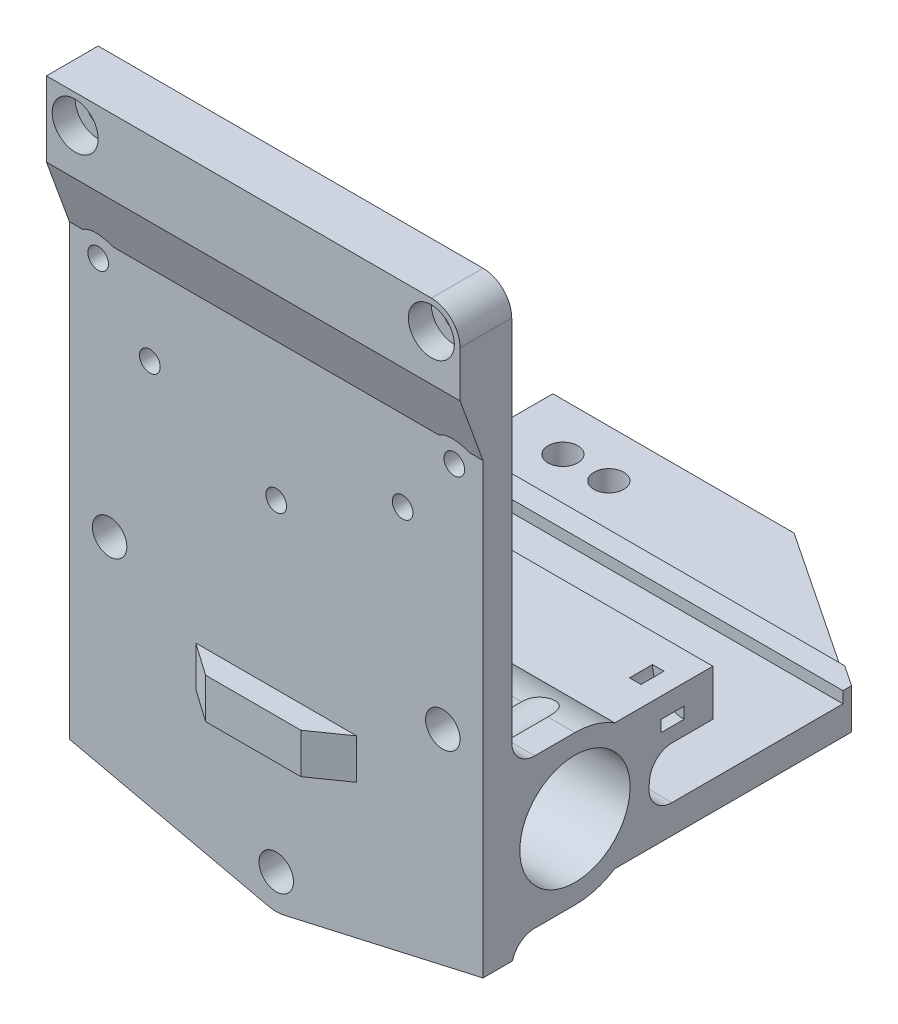
from build123d import *
from build123d.topology import SkipClean

# Parameters (mm, degrees)
SKETCH1_W               = 72
SKETCH1_H               = 102
BOSS_EXTRUDE1_DEPTH     = 5
BOSS_EXTRUDE4_DEPTH     = 72
SKETCH7_R               = 1.8
CUT_EXTRUDE4_DEPTH      = 64.071388125
SKETCH8_R               = 9.6
BOSS_EXTRUDE2_DEPTH     = 72
SKETCH9_R               = 3
CUT_EXTRUDE5_DEPTH      = 67.880490429
CUT_EXTRUDE5_DEPTH_BACK = 67.880490429
BOSS_EXTRUDE3_DEPTH     = 5
SKETCH11_R              = 5.5
CUT_EXTRUDE6_DEPTH      = 74.164198895
FILLET1_R               = 4
SKETCH13_R              = 4
CUT_EXTRUDE7_DEPTH      = 75.953318892
BOSS_EXTRUDE5_START     = -25.5
BOSS_EXTRUDE5_DEPTH     = 7
FILLET2_R               = 5
BOSS_EXTRUDE6_DEPTH     = 72
SKETCH17_W              = 72
SKETCH17_H              = 5
BOSS_EXTRUDE7_DEPTH     = 2
CHAMFER1_SIZE           = 1.1
CHAMFER1_SIZE2          = 1.905255888
SKETCH18_R              = 2.6
CUT_EXTRUDE9_DEPTH      = 2
CUT_EXTRUDE9_DEPTH_BACK = 127.588792976
BOSS_EXTRUDE8_DEPTH     = 72
FILLET3_R               = 4
SKETCH20_R              = 2.6
CUT_EXTRUDE10_DEPTH     = 8
SKETCH21_R              = 5.5
SKETCH21_R_2            = 3.5
CUT_EXTRUDE11_DEPTH     = 4
CHAMFER2_SIZE           = 1
SKETCH22_R              = 2.5
CUT_EXTRUDE12_DEPTH     = 127.588792976


with BuildPart() as part:
    # Sketch1 → Boss-Extrude1 (new body)
    with BuildSketch(Plane.XY):
        Rectangle(SKETCH1_W, SKETCH1_H)
    extrude(amount=BOSS_EXTRUDE1_DEPTH)

    # Sketch12 → Boss-Extrude4 (add)
    with BuildSketch(Plane.ZY.offset(36)):
        Polygon((5, 51), (9, 51), (9, 38), (5, 27.010090322), align=None)
    extrude(amount=-BOSS_EXTRUDE4_DEPTH)

    # Sketch7 → Cut-Extrude4 (cut, through all)
    with BuildSketch(Plane(origin=(0, 0, 0), x_dir=(-1, 0, 0), z_dir=(0, 0, -1))):
        with Locations((31, 24)):
            Circle(SKETCH7_R)
        with Locations((31, 46)):
            Circle(SKETCH7_R)
        with Locations((-31, 24)):
            Circle(SKETCH7_R)
        with Locations((-31, 46)):
            Circle(SKETCH7_R)
        with Locations((0, 3)):
            Circle(SKETCH7_R)
        with Locations((22, 13)):
            Circle(SKETCH7_R)
        with Locations((-22, 13)):
            Circle(SKETCH7_R)
    extrude(amount=-CUT_EXTRUDE4_DEPTH, mode=Mode.SUBTRACT)

    # Sketch8 → Boss-Extrude2 (add)
    with BuildSketch(Plane(origin=(36, 0, 0), x_dir=(0, 0, -1), z_dir=(1, 0, 0))):
        with BuildLine():
            Line((11, -22), (0, -22))
            Line((0, -22), (0, -48))
            Line((0, -48), (11, -48))
            ThreePointArc((11, -48), (24, -35), (11, -22))
        make_face()
        with Locations(Location((11, -35, 0), (0, 0, 90))):
            Circle(SKETCH8_R, mode=Mode.SUBTRACT)
    extrude(amount=-BOSS_EXTRUDE2_DEPTH)

    # Sketch9 → Cut-Extrude5 (cut, two sides)
    with BuildSketch(Plane(origin=(0, 0, 0), x_dir=(-1, 0, 0), z_dir=(0, 0, -1))) as cut_extrude5_sk:
        with Locations((-29, -17)):
            Circle(SKETCH9_R)
        with Locations((29, -17)):
            Circle(SKETCH9_R)
        with Locations((0, -53)):
            Circle(SKETCH9_R)
    extrude(amount=CUT_EXTRUDE5_DEPTH, mode=Mode.SUBTRACT)
    extrude(cut_extrude5_sk.sketch, amount=-CUT_EXTRUDE5_DEPTH_BACK, mode=Mode.SUBTRACT)

    # Sketch10 → Boss-Extrude3 (add)
    with BuildSketch(Plane(origin=(0, 0, 0), x_dir=(-1, 0, 0), z_dir=(0, 0, -1))):
        with BuildLine():
            Line((-36, -51), (-1.325102563, -58.851846136))
            ThreePointArc((-1.325102563, -58.851846136), (0, -59), (1.325102563, -58.851846136))
            Line((1.325102563, -58.851846136), (36, -51))
            Line((36, -51), (2.236067977, -51))
            ThreePointArc((2.236067977, -51), (0, -56), (-2.236067977, -51))
            Line((-2.236067977, -51), (-36, -51))
        make_face()
    extrude(amount=-BOSS_EXTRUDE3_DEPTH)

    # Sketch11 → Cut-Extrude6 (cut, through all)
    with BuildSketch(Plane(origin=(0, 0, 0), x_dir=(-1, 0, 0), z_dir=(0, 0, -1))):
        with Locations((-29, -17)):
            Circle(SKETCH11_R)
        with Locations((29, -17)):
            Circle(SKETCH11_R)
        with Locations((0, -53)):
            Circle(SKETCH11_R)
    extrude(amount=CUT_EXTRUDE6_DEPTH, mode=Mode.SUBTRACT)

    # Fillet1
    fillet1_edges = [part.edges().sort_by_distance(p)[0] for p in [
        (33.645643924, -22, 0),
        (0, -22, 0),
        (19.145643924, -48, 0),
        (-33.645643924, -22, 0),
        (-19.145643924, -48, 0),
    ]]
    fillet(fillet1_edges, radius=FILLET1_R)

    # Sketch13 → Cut-Extrude7 (cut, through all)
    with BuildSketch(Plane.XY.offset(5)):
        with Locations((-31, 24)):
            Circle(SKETCH13_R)
        with Locations((31, 24)):
            Circle(SKETCH13_R)
        with Locations(Location((31, 46, 0), (0, 0, 270))):
            Circle(SKETCH13_R)
        with Locations(Location((-31, 46, 0), (0, 0, 270))):
            Circle(SKETCH13_R)
    extrude(amount=CUT_EXTRUDE7_DEPTH, mode=Mode.SUBTRACT)

    # Fillet2
    fillet2_edges = [part.edges().sort_by_distance(p)[0] for p in [
        (36, 51, 4.5),
    ]]
    fillet(fillet2_edges, radius=FILLET2_R)

    # Sketch16 → Boss-Extrude6 (add)
    with SkipClean():  # the faces are left unmerged after this step: merging them gives an invalid solid
        with BuildSketch(Plane.ZY.offset(36)):
            with BuildLine():
                Line((-79.15, -41), (-18.493997598, -41))
                ThreePointArc((-18.493997598, -41), (-18.218315033, -41.328975279), (-17.92820323, -41.64529909))
                Line((-17.92820323, -41.64529909), (-17.92820323, -46))
                Line((-17.92820323, -46), (-79.15, -46))
                Line((-79.15, -46), (-79.15, -41))
            make_face()
        extrude(amount=-BOSS_EXTRUDE6_DEPTH)

    # Sketch17 → Boss-Extrude7 (add)
    with SkipClean():  # the faces are left unmerged after this step: merging them gives an invalid solid
        with BuildSketch(Plane(origin=(0, -41, 0), x_dir=(1, 0, 0), z_dir=(0, 1, 0))):
            with Locations((0, 60.15)):
                Rectangle(SKETCH17_W, SKETCH17_H)
        extrude(amount=BOSS_EXTRUDE7_DEPTH)

    # Chamfer1
    chamfer1_edges = [part.edges().sort_by_distance(p)[0] for p in [
        (0, -39, -62.65),
    ]]
    chamfer1_side = [part.faces().sort_by_distance(p)[0] for p in [
        (0, -39, -60.15),
    ]]
    chamfer(chamfer1_edges, length=CHAMFER1_SIZE, length2=CHAMFER1_SIZE2, reference=chamfer1_side[0])

    # Sketch18 → Cut-Extrude9 (cut, two sides)
    with SkipClean():  # the faces are left unmerged after this step: merging them gives an invalid solid
        with BuildSketch(Plane(origin=(0, -41, 0), x_dir=(1, 0, 0), z_dir=(0, 1, 0))) as cut_extrude9_sk:
            with Locations((-26, 70.9)):
                Circle(SKETCH18_R)
            with Locations((-18, 70.9)):
                Circle(SKETCH18_R)
            Polygon((6, 79.15), (36, 59.15), (36, 79.15), align=None)
        extrude(amount=CUT_EXTRUDE9_DEPTH, mode=Mode.SUBTRACT)
        extrude(cut_extrude9_sk.sketch, amount=-CUT_EXTRUDE9_DEPTH_BACK, mode=Mode.SUBTRACT)

    # Sketch19 → Boss-Extrude8 (add)
    with SkipClean():  # the faces are left unmerged after this step: merging them gives an invalid solid
        with BuildSketch(Plane(origin=(36, 0, 0), x_dir=(0, 0, -1), z_dir=(1, 0, 0))):
            with BuildLine():
                Line((17.92820323, -24), (35, -24))
                Line((35, -24), (35, -32))
                Line((35, -32), (20.119210492, -32))
                ThreePointArc((20.119210492, -32), (19.228117838, -30.054489223), (17.92820323, -28.35470091))
                Line((17.92820323, -28.35470091), (17.92820323, -24))
            make_face()
        extrude(amount=-BOSS_EXTRUDE8_DEPTH)

    # Fillet3
    fillet3_edges = [part.edges().sort_by_distance(p)[0] for p in [
        (0, -41, -22.532562595),
        (0, -32, -23.649110641),
    ]]
    fillet(fillet3_edges, radius=FILLET3_R)

    # Sketch20 → Cut-Extrude10 (cut)
    with SkipClean():  # the faces are left unmerged after this step: merging them gives an invalid solid
        with BuildSketch(Plane(origin=(0, 0, -35), x_dir=(-1, 0, 0), z_dir=(0, 0, -1))):
            with Locations((-16, -28)):
                Circle(SKETCH20_R)
            with Locations((16, -28)):
                Circle(SKETCH20_R)
        extrude(amount=-CUT_EXTRUDE10_DEPTH, mode=Mode.SUBTRACT)

    # Sketch21 → Cut-Extrude11 (cut)
    with SkipClean():  # the faces are left unmerged after this step: merging them gives an invalid solid
        with BuildSketch(Plane(origin=(0, 0, -30), x_dir=(-1, 0, 0), z_dir=(0, 0, -1))):
            with Locations((-36, -24)):
                Circle(SKETCH21_R)
            with Locations((-36, -24)):
                Circle(SKETCH21_R_2, mode=Mode.SUBTRACT)
            with Locations((36, -24)):
                Circle(SKETCH21_R)
            with Locations((36, -24)):
                Circle(SKETCH21_R_2, mode=Mode.SUBTRACT)
        extrude(amount=-CUT_EXTRUDE11_DEPTH, mode=Mode.SUBTRACT)

    # Chamfer2
    chamfer2_edges = [part.edges().sort_by_distance(p)[0] for p in [
        (18.6, -28, -35),
        (-13.4, -28, -35),
    ]]
    chamfer(chamfer2_edges, length=CHAMFER2_SIZE)

    # Sketch22 → Cut-Extrude12 (cut, through all)
    with SkipClean():  # the faces are left unmerged after this step: merging them gives an invalid solid
        with BuildSketch(Plane(origin=(0, -41, 0), x_dir=(1, 0, 0), z_dir=(0, 1, 0))):
            with Locations(Location((-30, 54.65, 0), (0, 0, 180))):
                Circle(SKETCH22_R)
            with Locations(Location((-30, 42.65, 0), (0, 0, 180))):
                Circle(SKETCH22_R)
        extrude(amount=-CUT_EXTRUDE12_DEPTH, mode=Mode.SUBTRACT)


with BuildPart() as body_2:
    # Sketch15 → Boss-Extrude5 (new body)
    with BuildSketch(Plane(origin=(0, 0, 0), x_dir=(1, 0, 0), z_dir=(0, 1, 0)).offset(BOSS_EXTRUDE5_START)):
        Polygon((-14, -5), (14, -5), (8.287407973, -9), (-8.287407973, -9), align=None)
    extrude(amount=-BOSS_EXTRUDE5_DEPTH)


solid = Compound([part.part, body_2.part])
